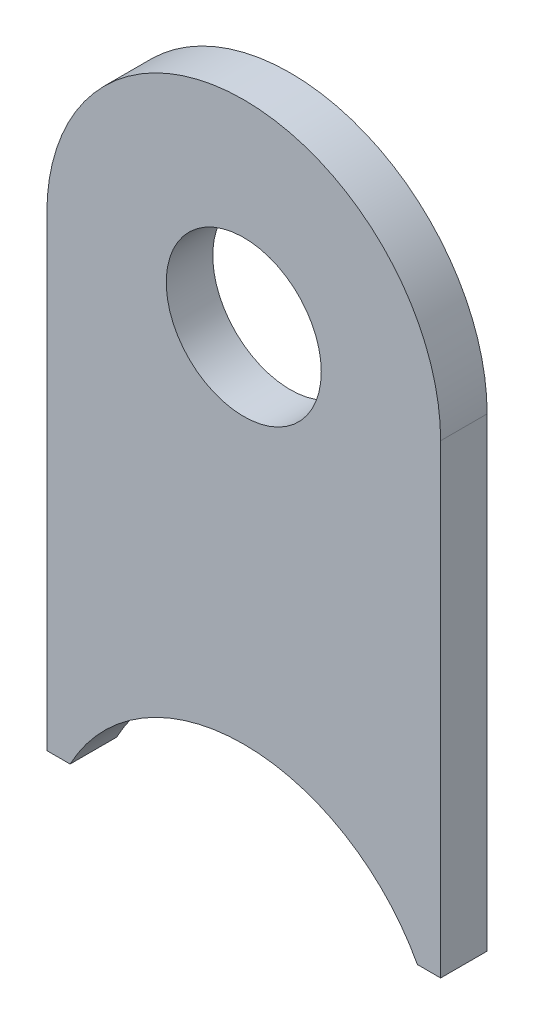
from build123d import *

# Parameters (mm, degrees)
BOSS_EXTRUDE1_DEPTH      = 1.5
BOSS_EXTRUDE1_DEPTH_BACK = 1.5
SKETCH1_R                = 5


with BuildPart() as part:
    # Sketch1 → Boss-Extrude1 (new, two sides: drawn at the far end of the back side and taken through both)
    with BuildSketch(Plane.XY.offset(-BOSS_EXTRUDE1_DEPTH_BACK)):
        with BuildLine():
            Line((-12.7, 0), (-12.7, -30.012513048))
            Line((-12.7, -30.012513048), (-11.2, -30.012513048))
            ThreePointArc((-11.2, -30.012513048), (0, -23.3), (11.2, -30.012513048))
            Line((11.2, -30.012513048), (12.7, -30.012513048))
            Line((12.7, -30.012513048), (12.7, 0))
            ThreePointArc((12.7, 0), (0, 12.7), (-12.7, 0))
        make_face()
        Circle(SKETCH1_R, mode=Mode.SUBTRACT)
    extrude(amount=BOSS_EXTRUDE1_DEPTH + BOSS_EXTRUDE1_DEPTH_BACK)


solid = part.part
